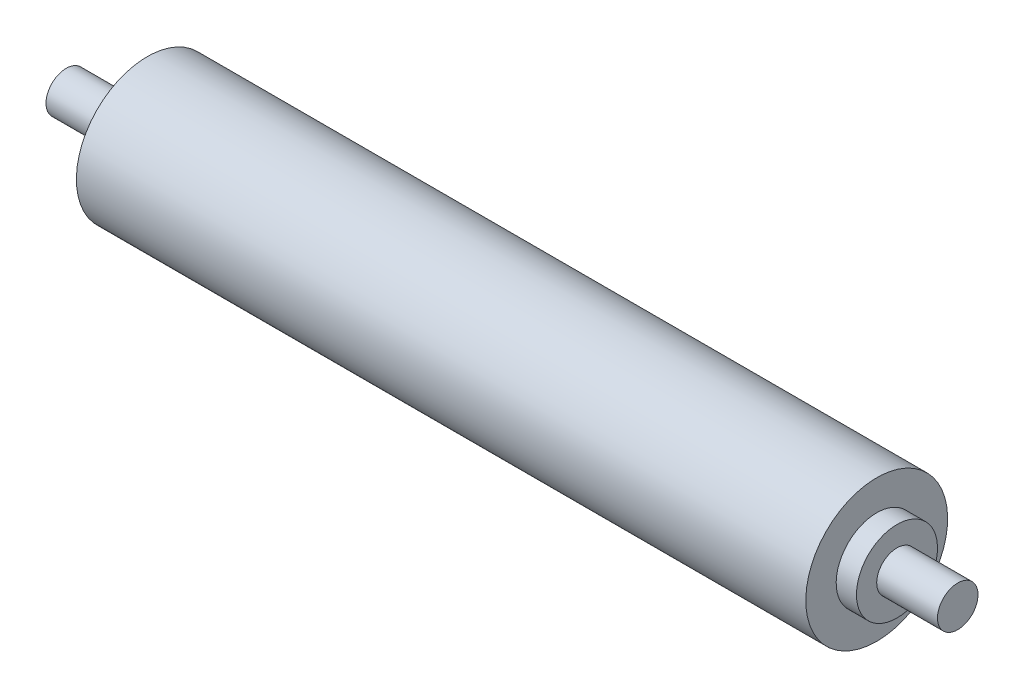
from build123d import *


with BuildPart() as part:
    # 草图1 → 旋转1 (revolve)
    with BuildSketch(Plane.XY):
        Polygon((-180, 35), (180, 35), (180, 20), (190, 20), (190, 10), (220, 10), (220, 0), (-220, 0), (-220, 10), (-190, 10), (-190, 20), (-180, 20), align=None)
    revolve(axis=Axis((-220, 0, 0), (1, 0, 0)))


solid = part.part
